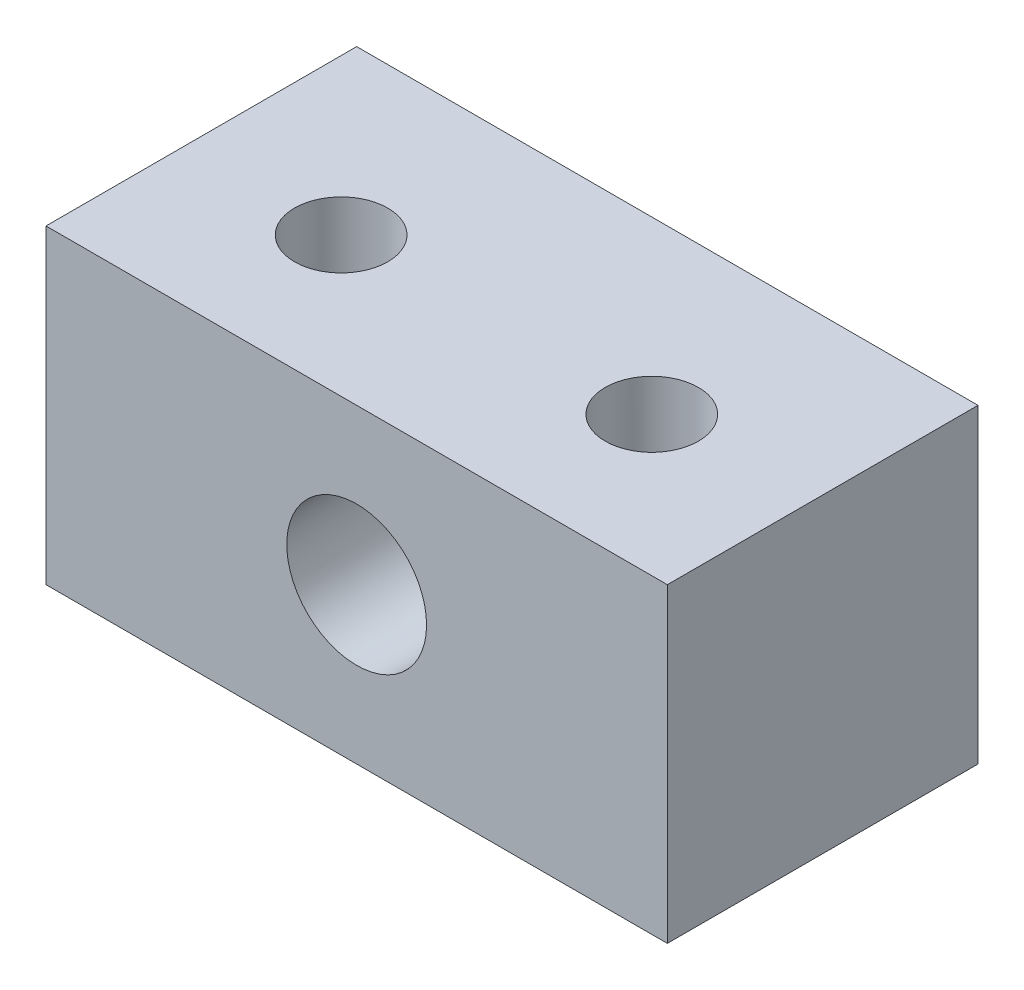
from build123d import *

# Parameters (mm, degrees)
ESQUISSE1_W                  = 20
ESQUISSE1_H                  = 10
BOSS_EXTRU_1_DEPTH           = 10
ESQUISSE2_R                  = 2.25
ENL_V_MAT_EXTRU_1_DEPTH      = 11
ESQUISSE3_R                  = 1.5
ENL_V_MAT_EXTRU_2_DEPTH      = 1
ENL_V_MAT_EXTRU_2_DEPTH_BACK = 11


with BuildPart() as part:
    # Esquisse1 → Boss.-Extru.1 (new body)
    with BuildSketch(Plane.XY):
        with Locations((10, 5)):
            Rectangle(ESQUISSE1_W, ESQUISSE1_H)
    extrude(amount=BOSS_EXTRU_1_DEPTH)

    # Esquisse2 → Enlèv. mat.-Extru.1 (cut, through all)
    with BuildSketch(Plane.XY.offset(10)):
        with Locations((10, 5)):
            Circle(ESQUISSE2_R)
    extrude(amount=-ENL_V_MAT_EXTRU_1_DEPTH, mode=Mode.SUBTRACT)

    # Esquisse3 → Enlèv. mat.-Extru.2 (cut, two sides)
    with BuildSketch(Plane(origin=(0, 10, 0), x_dir=(1, 0, 0), z_dir=(0, 1, 0))) as enl_v_mat_extru_2_sk:
        with Locations((5, -5.5)):
            Circle(ESQUISSE3_R)
        with Locations((15, -5.5)):
            Circle(ESQUISSE3_R)
    extrude(amount=ENL_V_MAT_EXTRU_2_DEPTH, mode=Mode.SUBTRACT)
    extrude(enl_v_mat_extru_2_sk.sketch, amount=-ENL_V_MAT_EXTRU_2_DEPTH_BACK, mode=Mode.SUBTRACT)


solid = part.part
